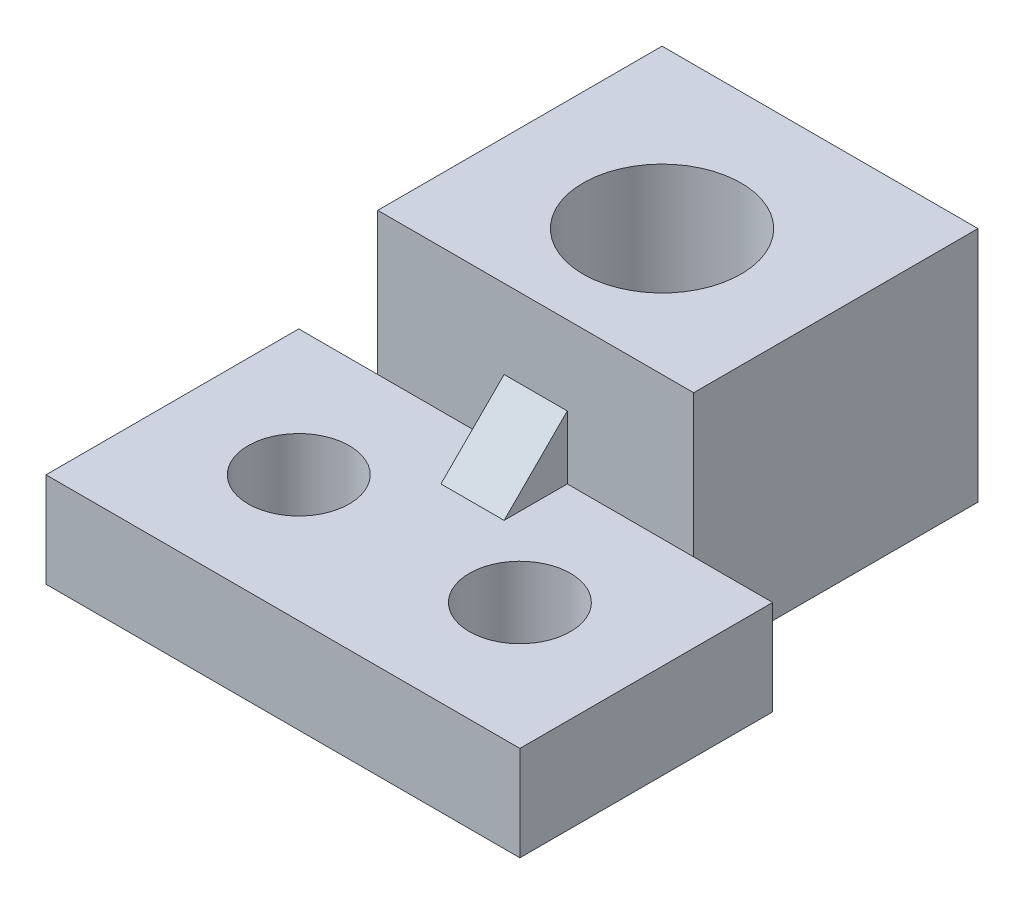
from build123d import *

# Parameters (mm, degrees)
SKETCH1_W           = 15
SKETCH1_H           = 8
SKETCH1_R           = 1.6
BOSS_EXTRUDE1_DEPTH = 3
SKETCH2_W           = 10
SKETCH2_H           = 9
SKETCH2_R           = 2.5
BOSS_EXTRUDE2_DEPTH = 7.5
BOSS_EXTRUDE3_DEPTH = 1


with BuildPart() as part:
    # Sketch1 → Boss-Extrude1 (new body)
    with BuildSketch(Plane(origin=(0, 0, 0), x_dir=(1, 0, 0), z_dir=(0, 1, 0))):
        with Locations((0, -1.0848967)):
            Rectangle(SKETCH1_W, SKETCH1_H)
        with Locations((-3.5, -1.0848967)):
            Circle(SKETCH1_R, mode=Mode.SUBTRACT)
        with Locations((3.5, -1.0848967)):
            Circle(SKETCH1_R, mode=Mode.SUBTRACT)
    extrude(amount=BOSS_EXTRUDE1_DEPTH)

    # Sketch2 → Boss-Extrude2 (add)
    with BuildSketch(Plane(origin=(0, 0, 0), x_dir=(1, 0, 0), z_dir=(0, 1, 0))):
        with Locations((0, 7.4151033)):
            Rectangle(SKETCH2_W, SKETCH2_H)
        with Locations((0, 6.9151033)):
            Circle(SKETCH2_R, mode=Mode.SUBTRACT)
    extrude(amount=BOSS_EXTRUDE2_DEPTH)

    # Sketch4 → Boss-Extrude3 (add, symmetric)
    with BuildSketch(Plane(origin=(0, 0, 0), x_dir=(0, 0, -1), z_dir=(1, 0, 0))):
        Polygon((2.9151033, 5), (0.9151033, 3), (2.9151033, 3), align=None)
    extrude(amount=BOSS_EXTRUDE3_DEPTH, both=True)


solid = part.part
